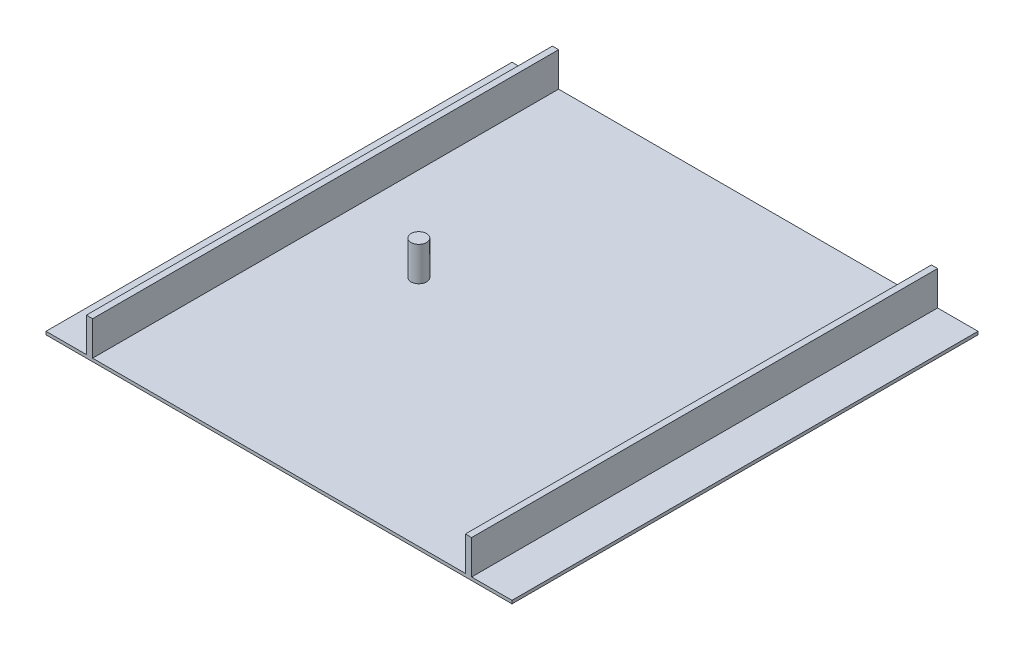
from build123d import *

# Parameters (mm, degrees)
SKETCH2_W           = 1500
SKETCH2_H           = 1500
BOSS_EXTRUDE1_DEPTH = 10
SKETCH3_W           = 20
SKETCH3_H           = 1500
BOSS_EXTRUDE2_DEPTH = 110
SKETCH4_R           = 25
BOSS_EXTRUDE3_DEPTH = 110


with BuildPart() as part:
    # Sketch2 → Boss-Extrude1 (new body)
    with BuildSketch(Plane(origin=(0, 0, 0), x_dir=(1, 0, 0), z_dir=(0, 1, 0))):
        Rectangle(SKETCH2_W, SKETCH2_H)
    extrude(amount=BOSS_EXTRUDE1_DEPTH)

    # Sketch3 → Boss-Extrude2 (add)
    with BuildSketch(Plane(origin=(0, 10, 0), x_dir=(1, 0, 0), z_dir=(0, 1, 0))):
        with Locations((-610, 0)):
            Rectangle(SKETCH3_W, SKETCH3_H)
        with Locations((610, 0)):
            Rectangle(SKETCH3_W, SKETCH3_H)
    extrude(amount=BOSS_EXTRUDE2_DEPTH)

    # Sketch4 → Boss-Extrude3 (add)
    with BuildSketch(Plane(origin=(0, 10, 0), x_dir=(1, 0, 0), z_dir=(0, 1, 0))):
        with Locations((-300, 0)):
            Circle(SKETCH4_R)
    extrude(amount=BOSS_EXTRUDE3_DEPTH)


solid = part.part
